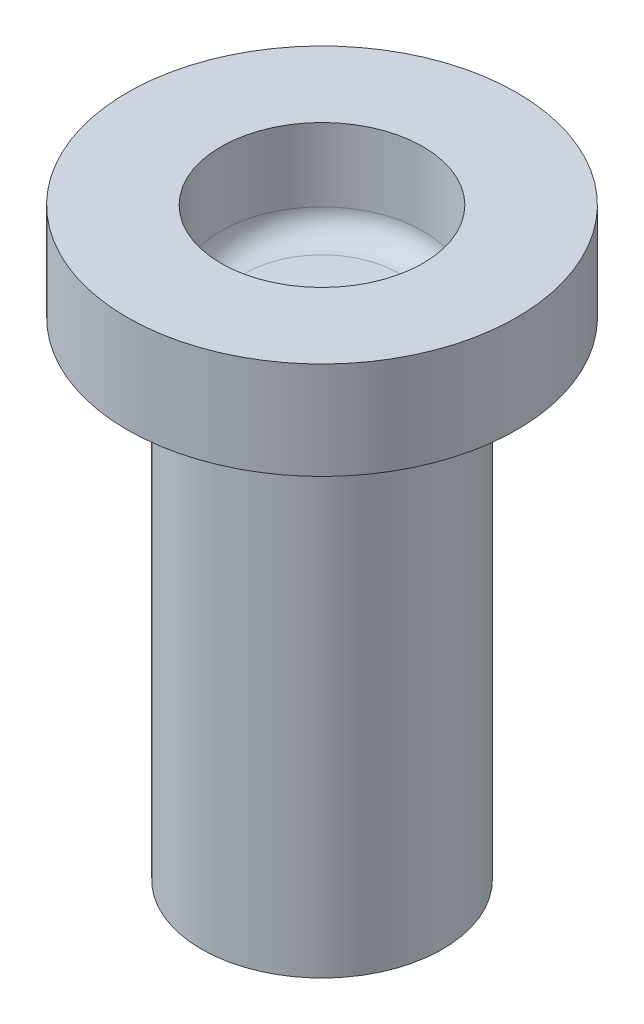
from build123d import *

# Parameters (mm, degrees)
SKETCH1_R           = 2.475
SKETCH1_R_2         = 1.5
BOSS_EXTRUDE1_DEPTH = 5
BOSS_EXTRUDE2_START = 5
SKETCH1_2_R         = 2.475
SKETCH1_2_R_2       = 1.5
BOSS_EXTRUDE2_DEPTH = 5
SKETCH2_R           = 4
SKETCH2_R_2         = 2.075
BOSS_EXTRUDE3_DEPTH = 2
FILLET1_R           = 0.5


with BuildPart() as part:
    # Sketch1 → Boss-Extrude1 (new body)
    with BuildSketch(Plane(origin=(0, 0, 0), x_dir=(1, 0, 0), z_dir=(0, 1, 0))):
        Circle(SKETCH1_R)
        Circle(SKETCH1_R_2, mode=Mode.SUBTRACT)
    extrude(amount=BOSS_EXTRUDE1_DEPTH)

    # Sketch1_2 → Boss-Extrude2 (add)
    with BuildSketch(Plane(origin=(0, 0, 0), x_dir=(1, 0, 0), z_dir=(0, 1, 0)).offset(BOSS_EXTRUDE2_START)):
        Circle(SKETCH1_2_R)
        Circle(SKETCH1_2_R_2, mode=Mode.SUBTRACT)
        Circle(SKETCH1_2_R_2)
    extrude(amount=BOSS_EXTRUDE2_DEPTH)

    # Sketch2 → Boss-Extrude3 (add)
    with BuildSketch(Plane(origin=(0, 10, 0), x_dir=(1, 0, 0), z_dir=(0, 1, 0))):
        Circle(SKETCH2_R)
        Circle(SKETCH2_R_2, mode=Mode.SUBTRACT)
    extrude(amount=BOSS_EXTRUDE3_DEPTH)

    # Fillet1
    fillet1_edges = [part.edges().sort_by_distance(p)[0] for p in [
        (-2.475, 10, 0),
        (-2.075, 10, 0),
    ]]
    fillet(fillet1_edges, radius=FILLET1_R)


solid = part.part
